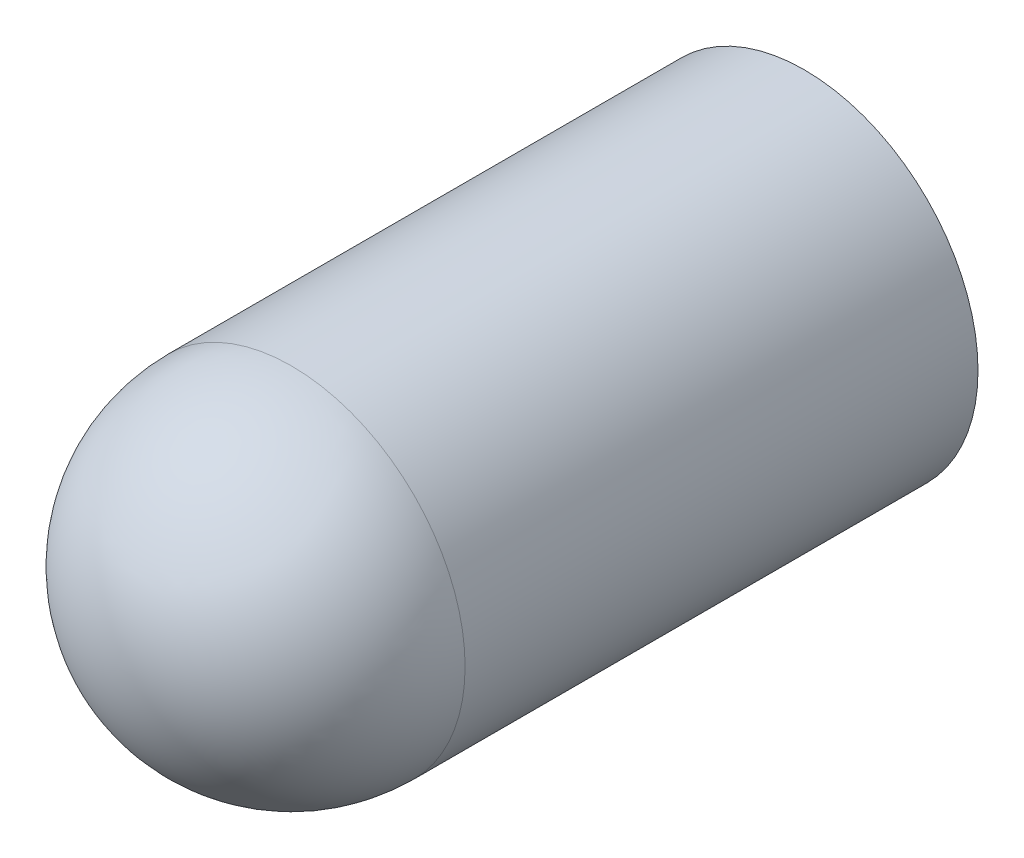
from build123d import *


with BuildPart() as part:
    # Sketch1 → Revolve2 (revolve)
    with BuildSketch(Plane(origin=(0, 0, 0), x_dir=(1, 0, 0), z_dir=(0, 1, 0))):
        with BuildLine():
            Line((1.27, 0), (1.27, -8.255))
            ThreePointArc((1.27, -8.255), (0.898025612, -9.153025612), (0, -9.525))
            Line((0, -9.525), (0, -11.049))
            ThreePointArc((0, -11.049), (1.975656347, -10.230656347), (2.794, -8.255))
            Line((2.794, -8.255), (2.794, 0))
            Line((2.794, 0), (1.27, 0))
        make_face()
    revolve(axis=Axis((0, 0, 0), (0, 0, 1)))


solid = part.part
